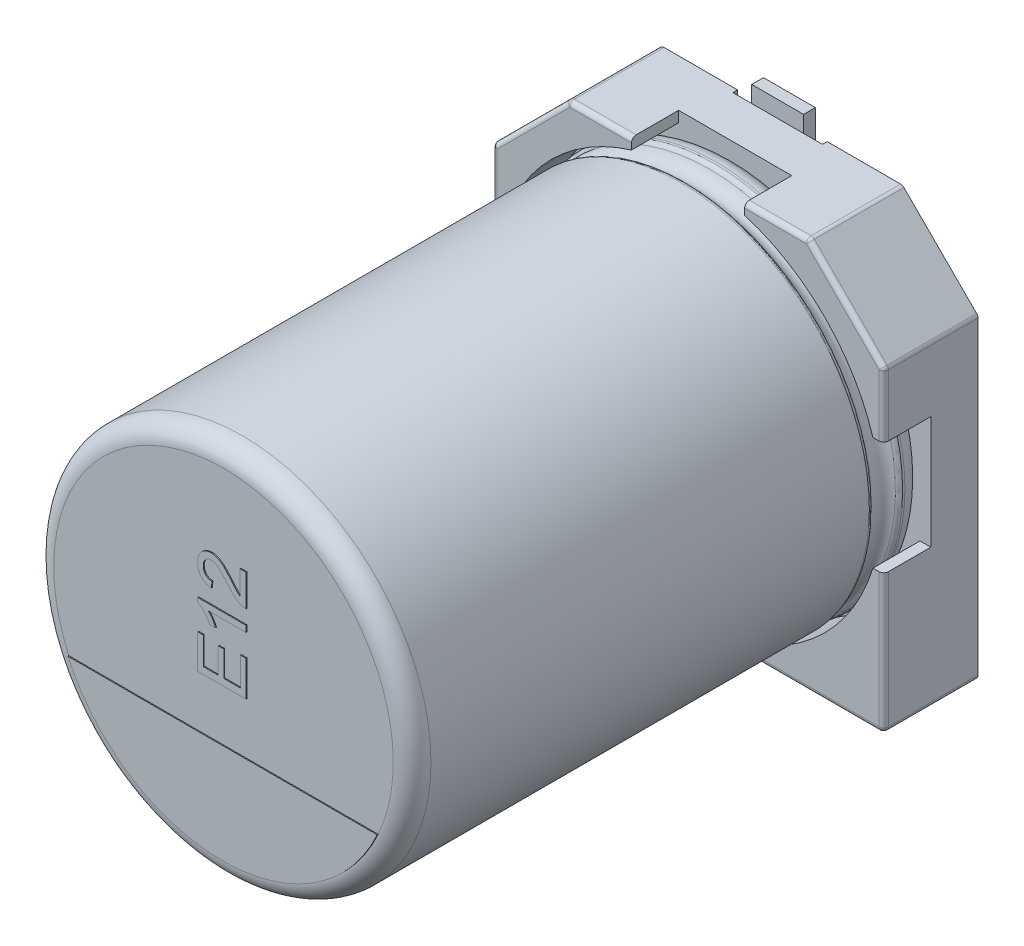
from build123d import *

# Parameters (mm, degrees)
BOSS_EXTRUDE1_DEPTH  = 1
BOSS_EXTRUDE2_DEPTH  = 1
SKETCH7_R            = 0.35
SPACER_PAD_DEPTH     = 0.15
SKETCH9_W            = 1.9
SKETCH9_H            = 2.65
CUT_EXTRUDE1_DEPTH   = 0.1
FILLET1_R            = 0.1
FILLET2_R            = 0.1
CATHODE_MARKER_DEPTH = 0.02
TEXT_2_DEPTH         = 0.02
SKETCH19_W           = 1.1
SKETCH19_H           = 2.9
BOSS_EXTRUDE6_DEPTH  = 0.25


with BuildPart() as part:
    # Sketch2 → Boss-Extrude1 (new body)
    with BuildSketch(Plane.XY):
        Polygon((-4.15, 2.55), (-2.55, 4.15), (2.55, 4.15), (4.15, 2.55), (4.15, -4.15), (-4.15, -4.15), align=None)
    extrude(amount=BOSS_EXTRUDE1_DEPTH)

    # Sketch4 → Boss-Extrude2 (add)
    with BuildSketch(Plane.XY.offset(1)):
        with BuildLine():
            Line((-4.15, 2.55), (-2.55, 4.15))
            Line((-2.55, 4.15), (-1.2, 4.15))
            Line((-1.2, 4.15), (-1.2, 3.920459157))
            ThreePointArc((-1.2, 3.920459157), (-2.899137803, 2.899137803), (-3.920459157, 1.2))
            Line((-3.920459157, 1.2), (-4.15, 1.2))
            Line((-4.15, 1.2), (-4.15, 2.55))
        make_face()
        with BuildLine():
            Line((2.55, 4.15), (4.15, 2.55))
            Line((4.15, 2.55), (4.15, 1.2))
            Line((4.15, 1.2), (3.920459157, 1.2))
            ThreePointArc((3.920459157, 1.2), (2.899137803, 2.899137803), (1.2, 3.920459157))
            Line((1.2, 3.920459157), (1.2, 4.15))
            Line((1.2, 4.15), (2.55, 4.15))
        make_face()
        with BuildLine():
            Line((4.15, -1.2), (4.15, -4.15))
            Line((4.15, -4.15), (1.2, -4.15))
            Line((1.2, -4.15), (1.2, -3.920459157))
            ThreePointArc((1.2, -3.920459157), (2.899137803, -2.899137803), (3.920459157, -1.2))
            Line((3.920459157, -1.2), (4.15, -1.2))
        make_face()
        with BuildLine():
            Line((-4.15, -1.2), (-4.15, -4.15))
            Line((-4.15, -4.15), (-1.2, -4.15))
            Line((-1.2, -4.15), (-1.2, -3.920459157))
            ThreePointArc((-1.2, -3.920459157), (-2.899137803, -2.899137803), (-3.920459157, -1.2))
            Line((-3.920459157, -1.2), (-4.15, -1.2))
        make_face()
    extrude(amount=BOSS_EXTRUDE2_DEPTH)

    # Sketch7 → Spacer Pad (add)
    with BuildSketch(Plane(origin=(0, 0, 0), x_dir=(1, 0, 0), z_dir=(0, 0, -1))):
        with Locations((-2.906501466, 2.844859418)):
            Circle(SKETCH7_R)
        with Locations((2.906501466, 2.844859418)):
            Circle(SKETCH7_R)
        with Locations((-2.906501466, -2.844859418)):
            Circle(SKETCH7_R)
        with Locations((2.906501466, -2.844859418)):
            Circle(SKETCH7_R)
    extrude(amount=SPACER_PAD_DEPTH)

    # Sketch9 → Cut-Extrude1 (cut)
    with BuildSketch(Plane(origin=(0, 0, 0), x_dir=(1, 0, 0), z_dir=(0, 0, -1))):
        with Locations((0, 2.825)):
            Rectangle(SKETCH9_W, SKETCH9_H)
        with Locations((0, -2.825)):
            Rectangle(SKETCH9_W, SKETCH9_H)
    extrude(amount=-CUT_EXTRUDE1_DEPTH, mode=Mode.SUBTRACT)

    # Fillet1
    fillet1_edges = [part.edges().sort_by_distance(p)[0] for p in [
        (4.15, -4.15, 1),
        (-4.15, -4.15, 1),
        (-4.15, 2.55, 1),
        (-2.55, 4.15, 1),
        (2.55, 4.15, 1),
        (4.15, 2.55, 1),
    ]]
    fillet(fillet1_edges, radius=FILLET1_R)

    # Sketch10 → Revolve1 (revolve)
    with BuildSketch(Plane(origin=(0, 0, 0), x_dir=(0, 0, -1), z_dir=(1, 0, 0))):
        with BuildLine():
            Line((-11.853626625, 0), (-1, 0))
            Line((-1, 0), (-1, 3.6))
            ThreePointArc((-1, 3.6), (-1.117157288, 3.882842712), (-1.4, 4))
            Line((-1.4, 4), (-1.449422929, 4))
            ThreePointArc((-1.449422929, 4), (-1.504479696, 3.983479053), (-1.541344666, 3.939375046))
            ThreePointArc((-1.541344666, 3.939375046), (-1.801990181, 3.767472047), (-2.062635697, 3.939375046))
            ThreePointArc((-2.062635697, 3.939375046), (-2.099500666, 3.983479053), (-2.154557434, 4))
            Line((-2.154557434, 4), (-11.453626625, 4))
            ThreePointArc((-11.453626625, 4), (-11.736469337, 3.882842712), (-11.853626625, 3.6))
            Line((-11.853626625, 3.6), (-11.853626625, 0))
        make_face()
    revolve(axis=Axis((0, 0, -18.9630778), (0, 0, 1)))

    # Fillet2
    fillet2_edges = [part.edges().sort_by_distance(p)[0] for p in [
        (2.625, -4.15, 2),
        (4.120710678, -4.120710678, 2),
        (4.15, 1.854289322, 2),
        (4.142387953, 2.546846987, 2),
        (1.854289322, 4.15, 2),
        (2.546846987, 4.142387953, 2),
        (-1.854289322, 4.15, 2),
        (-2.546846987, 4.142387953, 2),
        (-3.35, 3.35, 2),
        (-4.142387953, 2.546846987, 2),
        (-4.15, -2.625, 2),
        (-4.120710678, -4.120710678, 2),
        (4.15, -2.625, 2),
        (3.35, 3.35, 2),
        (-4.15, 1.854289322, 2),
        (-2.625, -4.15, 2),
    ]]
    fillet(fillet2_edges, radius=FILLET2_R)

    # Sketch13 → Cathode marker (add)
    with BuildSketch(Plane.XY.offset(11.853626625)):
        with BuildLine():
            Line((-3.280894476, -1.481800067), (3.280894476, -1.481800067))
            ThreePointArc((3.280894476, -1.481800067), (0, -3.6), (-3.280894476, -1.481800067))
        make_face()
    extrude(amount=CATHODE_MARKER_DEPTH)

    # Sketch15 → Text 2 (add)
    with BuildSketch(Plane.XY.offset(11.853626625)):
        Polygon((0.5, -0.381462215), (-0.527327474, -0.381462215), (-0.527327474, 0.342935363), (-0.408789689, 0.342935363), (-0.408789689, -0.236582699), (-0.092688927, -0.236582699), (-0.092688927, 0.303422768), (0.025848858, 0.303422768), (0.025848858, -0.236582699), (0.381462215, -0.236582699), (0.381462215, 0.369277093), (0.5, 0.369277093), align=None)
        with BuildLine():
            Line((0.5, 0.975136886), (0.5, 0.843428235))
            Line((0.5, 0.843428235), (-0.300541641, 0.843428235))
            add(Edge.make_bspline(
                [(-0.300541641, 0.843428235), (-0.293231008, 0.835842223), (-0.278036657, 0.820075527), (-0.256498368, 0.793500467), (-0.234933587, 0.763635908), (-0.213972558, 0.731200604), (-0.193975357, 0.698239233), (-0.17626551, 0.666212427), (-0.16122985, 0.635905104), (-0.153017422, 0.615935207), (-0.149076693, 0.606352664)],
                knots=[0, 0, 0, 0, 0.893410138, 1.856855062, 2.898678959, 4.017251132, 5.132047586, 6.168690112, 7.121247105, 8, 8, 8, 8], degree=3))
            Line((-0.149076693, 0.606352664), (-0.270495605, 0.606352664))
            add(Edge.make_bspline(
                [(-0.270495605, 0.606352664), (-0.278975965, 0.622807623), (-0.295690253, 0.655239372), (-0.324502419, 0.701148466), (-0.356038954, 0.743792464), (-0.389687464, 0.782917924), (-0.424153619, 0.81780935), (-0.458713989, 0.84744292), (-0.492500166, 0.87204352), (-0.516061848, 0.884428006), (-0.527327474, 0.890349442)],
                knots=[0, 0, 0, 0, 1.141359047, 2.249551097, 3.338622382, 4.409719606, 5.42990334, 6.36011437, 7.215916014, 8, 8, 8, 8], degree=3))
            Line((-0.527327474, 0.890349442), (-0.527327474, 0.975136886))
            Line((-0.527327474, 0.975136886), (0.5, 0.975136886))
        make_face()
        with BuildLine():
            Line((0.368291349, 1.949780899), (0.5, 1.949780899))
            Line((0.5, 1.949780899), (0.5, 1.278066782))
            add(Edge.make_bspline(
                [(0.5, 1.278066782), (0.492171624, 1.278048518), (0.476609384, 1.278012212), (0.453503009, 1.280711649), (0.430681783, 1.284779667), (0.415992941, 1.289492), (0.408627124, 1.291855031)],
                knots=[0, 0, 0, 0, 1.010600758, 2.009000657, 3.001600101, 4, 4, 4, 4], degree=3))
            add(Edge.make_bspline(
                [(0.408627124, 1.291855031), (0.396584863, 1.296201497), (0.372122637, 1.305030755), (0.336858288, 1.323189065), (0.301599244, 1.34413993), (0.272965244, 1.364814373), (0.250100299, 1.38366477), (0.232215155, 1.399480616), (0.213906424, 1.417005313), (0.195178947, 1.436227401), (0.175910995, 1.456961129), (0.156038437, 1.479235006), (0.135931585, 1.503311989), (0.122603928, 1.520120246), (0.115781171, 1.528724807)],
                knots=[0, 0, 0, 0, 1.204682444, 2.447149603, 3.728063212, 5.065745198, 5.768097617, 6.518745349, 7.313897871, 8.154576377, 9.046034033, 9.979646649, 10.965731253, 12, 12, 12, 12], degree=3))
            add(Edge.make_bspline(
                [(0.115781171, 1.528724807), (0.104655179, 1.541943537), (0.083231375, 1.567397041), (0.051440447, 1.603341396), (0.021920728, 1.636170643), (-0.005844993, 1.665362321), (-0.031587993, 1.691154191), (-0.055248077, 1.713609979), (-0.076757278, 1.732912959), (-0.096875759, 1.748858252), (-0.115869126, 1.762206028), (-0.134293391, 1.773794817), (-0.152793693, 1.783097922), (-0.171018699, 1.791081384), (-0.189040379, 1.797275027), (-0.207020154, 1.80163395), (-0.224787825, 1.80445068), (-0.236666661, 1.80475282), (-0.242507517, 1.804901384)],
                knots=[0, 0, 0, 0, 1.782511555, 3.432339066, 4.950556168, 6.337242158, 7.588364383, 8.709771971, 9.70247892, 10.569050646, 11.3564271, 12.096888545, 12.812232926, 13.490631961, 14.148641375, 14.7751826, 15.397753892, 16, 16, 16, 16], degree=3))
            add(Edge.make_bspline(
                [(-0.242507517, 1.804901384), (-0.248281178, 1.804758397), (-0.259608786, 1.804477864), (-0.276186441, 1.801815627), (-0.292152005, 1.798110793), (-0.3072139, 1.79211655), (-0.321833794, 1.78499758), (-0.335535371, 1.775773734), (-0.348836285, 1.765333006), (-0.361041005, 1.753136066), (-0.372476027, 1.739905649), (-0.382043562, 1.725184563), (-0.39031717, 1.709697718), (-0.397264619, 1.693288181), (-0.402301048, 1.675712685), (-0.405976885, 1.657194013), (-0.408302294, 1.637716956), (-0.40862476, 1.624425942), (-0.408789689, 1.617628146)],
                knots=[0, 0, 0, 0, 0.987973548, 1.938350371, 2.870100611, 3.788647624, 4.708095761, 5.649791829, 6.611214459, 7.599816467, 8.600146238, 9.60047601, 10.599079585, 11.604913276, 12.645813302, 13.724097821, 14.835971573, 16, 16, 16, 16], degree=3))
            add(Edge.make_bspline(
                [(-0.408789689, 1.617628146), (-0.40862557, 1.61048725), (-0.408304378, 1.596511991), (-0.405969781, 1.576082832), (-0.402394194, 1.556692918), (-0.396958126, 1.538369985), (-0.390017565, 1.521232491), (-0.381660425, 1.505078574), (-0.371833372, 1.490028119), (-0.360287899, 1.47629422), (-0.347459849, 1.463884379), (-0.333496156, 1.45287492), (-0.318088523, 1.443783375), (-0.301533418, 1.436437271), (-0.28393451, 1.430382815), (-0.265117004, 1.4260423), (-0.245105463, 1.423666529), (-0.231400392, 1.423189859), (-0.224397578, 1.422946297)],
                knots=[0, 0, 0, 0, 1.130801575, 2.213061782, 3.252933619, 4.249917472, 5.234510032, 6.17726912, 7.126517163, 8.075267631, 9.012689889, 9.949419277, 10.884824487, 11.837981854, 12.813782694, 13.828488442, 14.890433304, 16, 16, 16, 16], degree=3))
            Line((-0.224397578, 1.422946297), (-0.237568443, 1.291237647))
            add(Edge.make_bspline(
                [(-0.237568443, 1.291237647), (-0.24904719, 1.292585193), (-0.271378105, 1.295206727), (-0.303720398, 1.301736999), (-0.333809028, 1.310903488), (-0.362058757, 1.321876782), (-0.388005438, 1.335615485), (-0.412169544, 1.351235413), (-0.433950691, 1.369441754), (-0.453727379, 1.38970225), (-0.470891467, 1.412225596), (-0.486127765, 1.436476464), (-0.498828506, 1.46273755), (-0.509361258, 1.4907582), (-0.517348257, 1.520621805), (-0.523076894, 1.552280795), (-0.526607783, 1.585787583), (-0.527084154, 1.608770236), (-0.527327474, 1.620509273)],
                knots=[0, 0, 0, 0, 1.130730993, 2.199739822, 3.223355253, 4.205635214, 5.160465258, 6.091399258, 7.016214058, 7.932437584, 8.856204186, 9.781944312, 10.73064304, 11.705670886, 12.707145581, 13.751268262, 14.851396981, 16, 16, 16, 16], degree=3))
            add(Edge.make_bspline(
                [(-0.527327474, 1.620509273), (-0.52712405, 1.632388825), (-0.526727779, 1.655530263), (-0.522673132, 1.689251056), (-0.516358058, 1.721067558), (-0.507556774, 1.751096399), (-0.496015678, 1.779160195), (-0.481915024, 1.805280425), (-0.465392543, 1.829577919), (-0.446249206, 1.851645252), (-0.425353076, 1.871548104), (-0.403045107, 1.888975081), (-0.37940145, 1.903630993), (-0.354725388, 1.915875017), (-0.328682822, 1.925236137), (-0.301469318, 1.93165133), (-0.273039491, 1.936063585), (-0.253637851, 1.936425463), (-0.243742286, 1.936610034)],
                knots=[0, 0, 0, 0, 1.195413282, 2.328672114, 3.413490698, 4.457927086, 5.473612634, 6.462365753, 7.441157041, 8.42539015, 9.397434444, 10.3422866, 11.269742116, 12.193178192, 13.110630063, 14.048592791, 15.004708964, 16, 16, 16, 16], degree=3))
            add(Edge.make_bspline(
                [(-0.243742286, 1.936610034), (-0.233575811, 1.936327557), (-0.213220425, 1.935761978), (-0.182799605, 1.931326689), (-0.152753848, 1.923810915), (-0.122679161, 1.913628618), (-0.092323518, 1.90008116), (-0.061437605, 1.882668685), (-0.029892588, 1.861267498), (-0.003243258, 1.840467299), (0.019225253, 1.821296784), (0.037719176, 1.804161813), (0.057588605, 1.78457564), (0.079062929, 1.762817781), (0.101646668, 1.738346467), (0.125957864, 1.711736753), (0.151384518, 1.682434665), (0.168753578, 1.662092058), (0.177725396, 1.651584283)],
                knots=[0, 0, 0, 0, 0.927158598, 1.856363277, 2.797335015, 3.749167701, 4.749227661, 5.825023649, 6.979171586, 8.223362362, 8.906844726, 9.672958766, 10.52256342, 11.451810239, 12.461281865, 13.559912207, 14.739596516, 16, 16, 16, 16], degree=3))
            add(Edge.make_bspline(
                [(0.177725396, 1.651584283), (0.185029786, 1.642568404), (0.198985808, 1.625342352), (0.219510177, 1.601160163), (0.237812789, 1.579072115), (0.25415447, 1.559350325), (0.268864412, 1.542154634), (0.281772612, 1.527476096), (0.292659395, 1.515047219), (0.309621164, 1.496488027), (0.333822946, 1.473059073), (0.357137714, 1.455588087), (0.368291349, 1.44723008)],
                knots=[0, 0, 0, 0, 1.242067915, 2.373138023, 3.395138797, 4.312776638, 5.114836229, 5.81737152, 6.405241861, 6.883397567, 8.50903741, 10, 10, 10, 10], degree=3))
            Line((0.368291349, 1.44723008), (0.368291349, 1.949780899))
        make_face()
    extrude(amount=TEXT_2_DEPTH)

    # Sketch19 → Boss-Extrude6 (add)
    with BuildSketch(Plane(origin=(0, 0, 0.1), x_dir=(1, 0, 0), z_dir=(0, 0, -1))):
        with Locations((0, 3.05)):
            Rectangle(SKETCH19_W, SKETCH19_H)
        with Locations((0, -3.05)):
            Rectangle(SKETCH19_W, SKETCH19_H)
    extrude(amount=BOSS_EXTRUDE6_DEPTH)


solid = part.part
